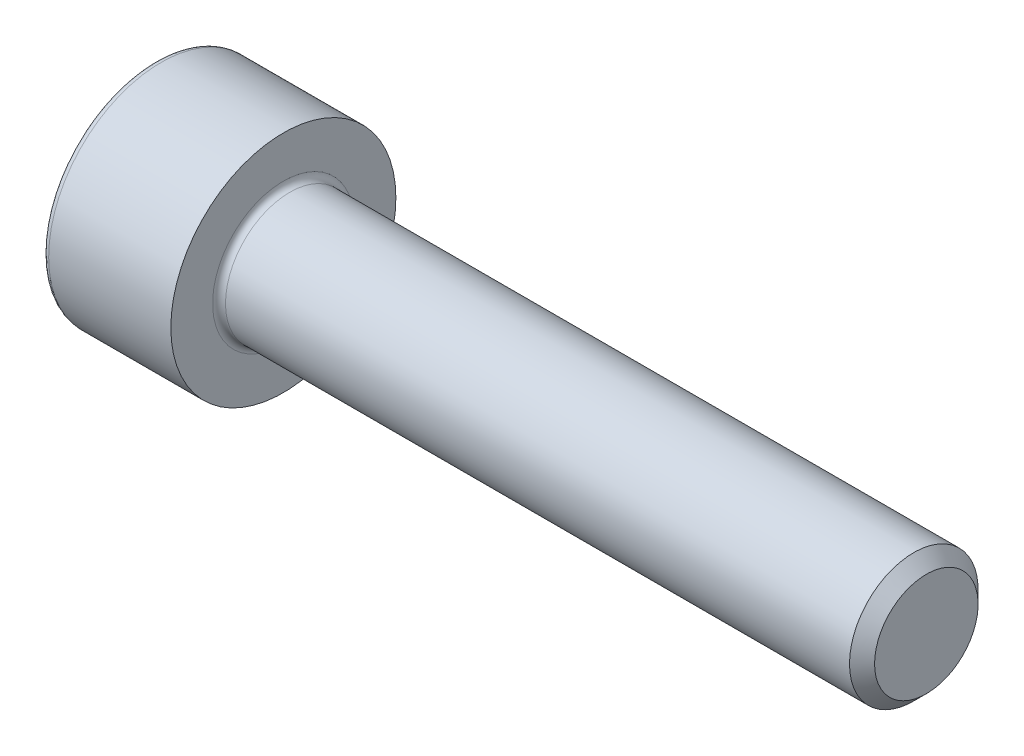
from build123d import *

# Parameters (mm, degrees)
FILLET1_R   = 0.2
FILLET2_R   = 0.2
HEX_2_DEPTH = 2


with BuildPart() as part:
    # BodySke → Base-Revolve (revolve)
    with BuildSketch(Plane.XY):
        Polygon((0, 0), (0, 3.5), (4, 3.5), (4, 2), (23.61, 2), (24, 1.61), (24, 0), align=None)
    revolve(axis=Axis((-31.75, 0, 0), (1, 0, 0)))

    # Fillet1
    fillet1_edges = [part.edges().sort_by_distance(p)[0] for p in [
        (4, -2, 0),
    ]]
    fillet(fillet1_edges, radius=FILLET1_R)

    # Fillet2
    fillet2_edges = [part.edges().sort_by_distance(p)[0] for p in [
        (0, -3.5, 0),
    ]]
    fillet(fillet2_edges, radius=FILLET2_R)

    # Sketch2 → Hex-PreBroach (revolve, cut)
    with BuildSketch(Plane.XY):
        Polygon((0, 1.5355), (2, 1.5355), (2.886521338, 0), (0, 0), align=None)
    revolve(axis=Axis((0, 0, 0), (1, 0, 0)), mode=Mode.SUBTRACT)

    # Sketch3 → Hex 2 (cut)
    with BuildSketch(Plane(origin=(0, 0, 0), x_dir=(0, 0.5, 0.866025404), z_dir=(-1, 0, 0))):
        Polygon((0.886521338, 1.5355), (-0.886521338, 1.5355), (-1.773042677, 0), (-0.886521338, -1.5355), (0.886521338, -1.5355), (1.773042677, 0), align=None)
    extrude(amount=-HEX_2_DEPTH, mode=Mode.SUBTRACT)


solid = part.part
